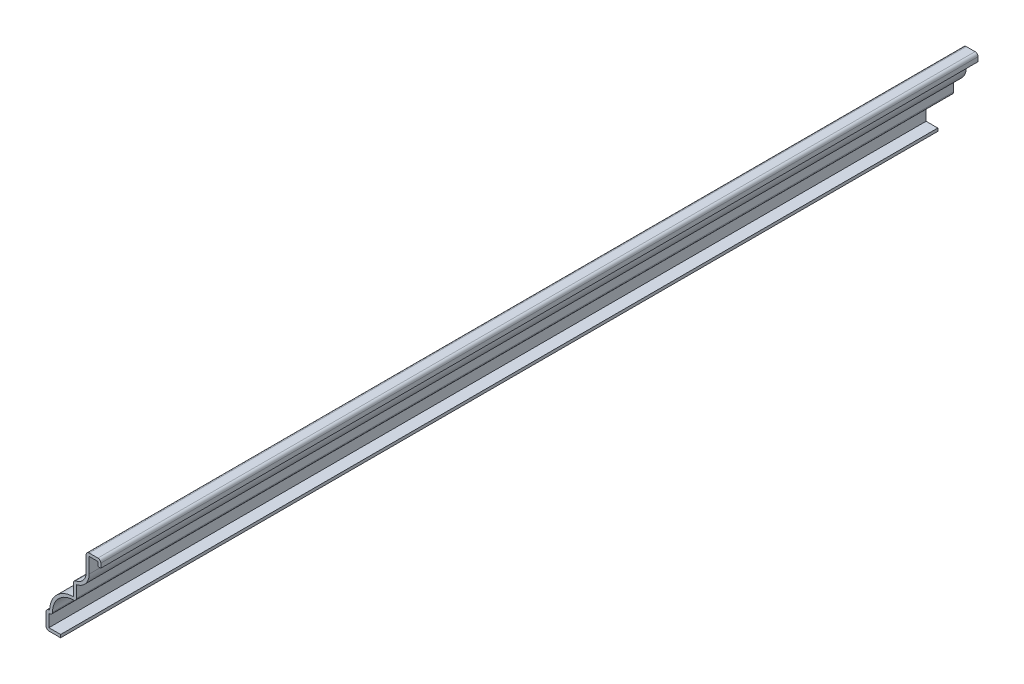
from build123d import *

# Parameters (mm, degrees)
EXTRUDE_THIN1_DEPTH = 381
FILLET1_R           = 1.27


with BuildPart() as part:
    # Sketch1 → Extrude-Thin1 (new body)
    with BuildSketch(Plane.XY):
        with BuildLine():
            Line((-17.4625, 0), (-23.8125, 0))
            Line((-23.8125, 0), (-23.8125, 7.9375))
            Line((-23.8125, 7.9375), (-22.225, 7.9375))
            ThreePointArc((-22.225, 7.9375), (-19.202708098, 15.233958098), (-11.90625, 18.25625))
            Line((-11.90625, 18.25625), (-11.90625, 24.60625))
            ThreePointArc((-11.90625, 24.60625), (-7.977387947, 26.233637947), (-6.35, 30.1625))
            Line((-6.35, 30.1625), (-6.35, 38.1))
            Line((-6.35, 38.1), (0, 38.1))
            Line((0, 38.1), (0, 34.925))
            Line((0, 34.925), (-1.27, 34.925))
            Line((-1.27, 34.925), (-1.27, 36.83))
            Line((-1.27, 36.83), (-5.08, 36.83))
            Line((-5.08, 36.83), (-5.08, 30.1625))
            ThreePointArc((-5.08, 30.1625), (-6.649491181, 25.807712315), (-10.63625, 23.45542992))
            Line((-10.63625, 23.45542992), (-10.63625, 16.896683923))
            ThreePointArc((-10.63625, 16.896683923), (-18.304682486, 14.335932486), (-20.865433923, 6.6675))
            Line((-20.865433923, 6.6675), (-22.5425, 6.6675))
            Line((-22.5425, 6.6675), (-22.5425, 1.27))
            Line((-22.5425, 1.27), (-17.4625, 1.27))
            Line((-17.4625, 1.27), (-17.4625, 0))
        make_face()
    extrude(amount=-EXTRUDE_THIN1_DEPTH)

    # Fillet1
    fillet1_edges = [part.edges().sort_by_distance(p)[0] for p in [
        (-10.63625, 16.896683923, -190.5),
        (-20.865433923, 6.6675, -190.5),
        (-23.8125, 0, -190.5),
        (-23.8125, 7.9375, -190.5),
        (-11.90625, 24.60625, -190.5),
        (-6.35, 38.1, -190.5),
        (0, 38.1, -190.5),
    ]]
    fillet(fillet1_edges, radius=FILLET1_R)


solid = part.part
